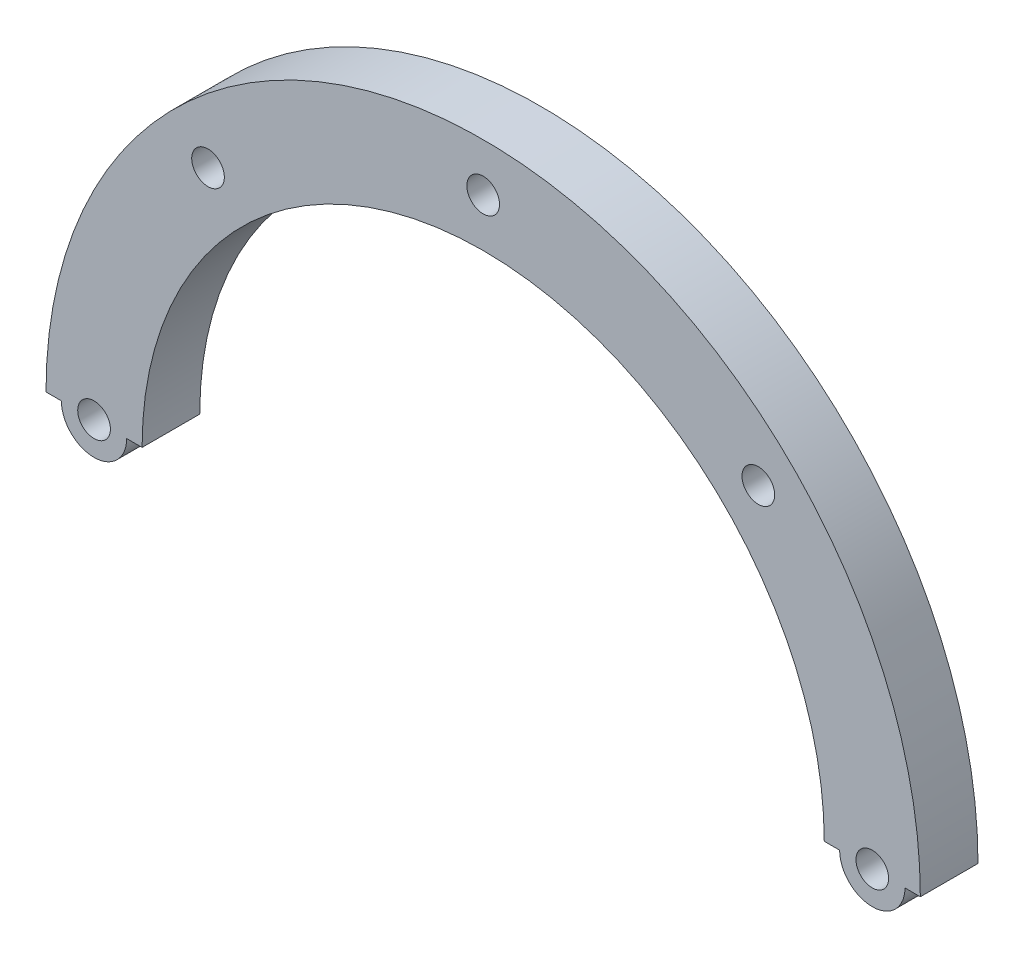
from build123d import *

# Parameters (mm, degrees)
SALIENTE_EXTRUIR1_DEPTH = 6
CROQUIS2_R              = 1.7
CORTAR_EXTRUIR1_DEPTH   = 7
CROQUIS3_R              = 3.4
CROQUIS3_R_2            = 1.7
SALIENTE_EXTRUIR2_DEPTH = 6


with BuildPart() as part:
    # Croquis1 → Saliente-Extruir1 (new body)
    with BuildSketch(Plane.XY):
        with BuildLine():
            Line((-45.5, 0), (-35.5, 0))
            ThreePointArc((-35.5, 0), (0, 35.5), (35.5, 0))
            Line((35.5, 0), (45.5, 0))
            ThreePointArc((45.5, 0), (0, 45.5), (-45.5, 0))
        make_face()
    extrude(amount=SALIENTE_EXTRUIR1_DEPTH)

    # Croquis2 → Cortar-Extruir1 (cut, through all)
    with BuildSketch(Plane.XY.offset(6)):
        with Locations((0, 40.5)):
            Circle(CROQUIS2_R)
        with Locations((28.637824638, 28.637824638)):
            Circle(CROQUIS2_R)
        with Locations((40.5, 0)):
            Circle(CROQUIS2_R)
        with Locations((-40.5, 0)):
            Circle(CROQUIS2_R)
        with Locations((-28.637824638, 28.637824638)):
            Circle(CROQUIS2_R)
    extrude(amount=-CORTAR_EXTRUIR1_DEPTH, mode=Mode.SUBTRACT)

    # Croquis3 → Saliente-Extruir2 (add)
    with BuildSketch(Plane.XY.offset(6)):
        with Locations((-40.5, 0)):
            Circle(CROQUIS3_R)
        with Locations((-40.5, 0)):
            Circle(CROQUIS3_R_2, mode=Mode.SUBTRACT)
        with Locations((40.5, 0)):
            Circle(CROQUIS3_R)
        with Locations((40.5, 0)):
            Circle(CROQUIS3_R_2, mode=Mode.SUBTRACT)
    extrude(amount=-SALIENTE_EXTRUIR2_DEPTH)


solid = part.part
